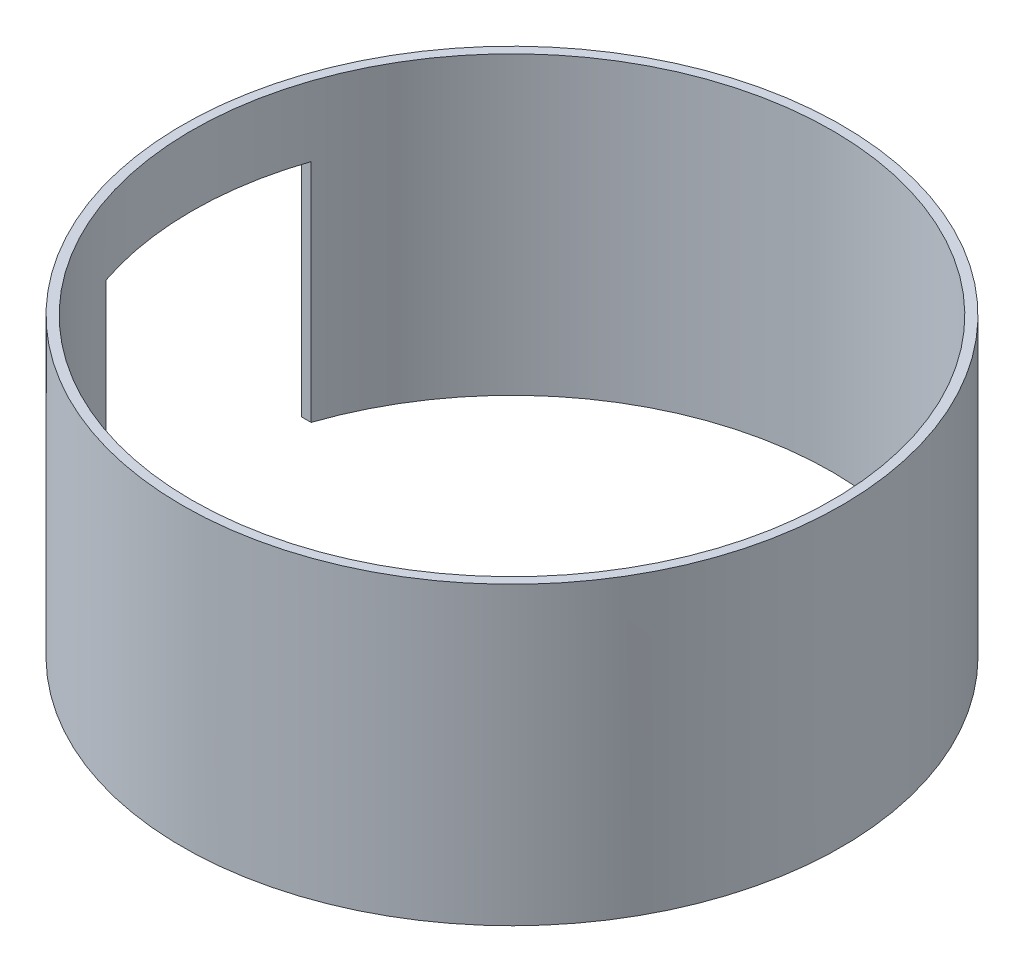
from build123d import *

# Parameters (mm, degrees)
SKETCH1_R           = 35.375
SKETCH1_R_2         = 34.375
BOSS_EXTRUDE1_DEPTH = 31.75
SKETCH2_W           = 22
SKETCH2_H           = 24.25
CUT_EXTRUDE1_DEPTH  = 43


with BuildPart() as part:
    # Sketch1 → Boss-Extrude1 (new body)
    with BuildSketch(Plane(origin=(0, 0, 0), x_dir=(1, 0, 0), z_dir=(0, 1, 0))):
        Circle(SKETCH1_R)
        Circle(SKETCH1_R_2, mode=Mode.SUBTRACT)
    extrude(amount=BOSS_EXTRUDE1_DEPTH)

    # Sketch2 → Cut-Extrude1 (cut)
    with BuildSketch(Plane(origin=(0, 0, 0), x_dir=(0, 0, -1), z_dir=(1, 0, 0))):
        with Locations((0, 12.125)):
            Rectangle(SKETCH2_W, SKETCH2_H)
    extrude(amount=-CUT_EXTRUDE1_DEPTH, mode=Mode.SUBTRACT)


solid = part.part
